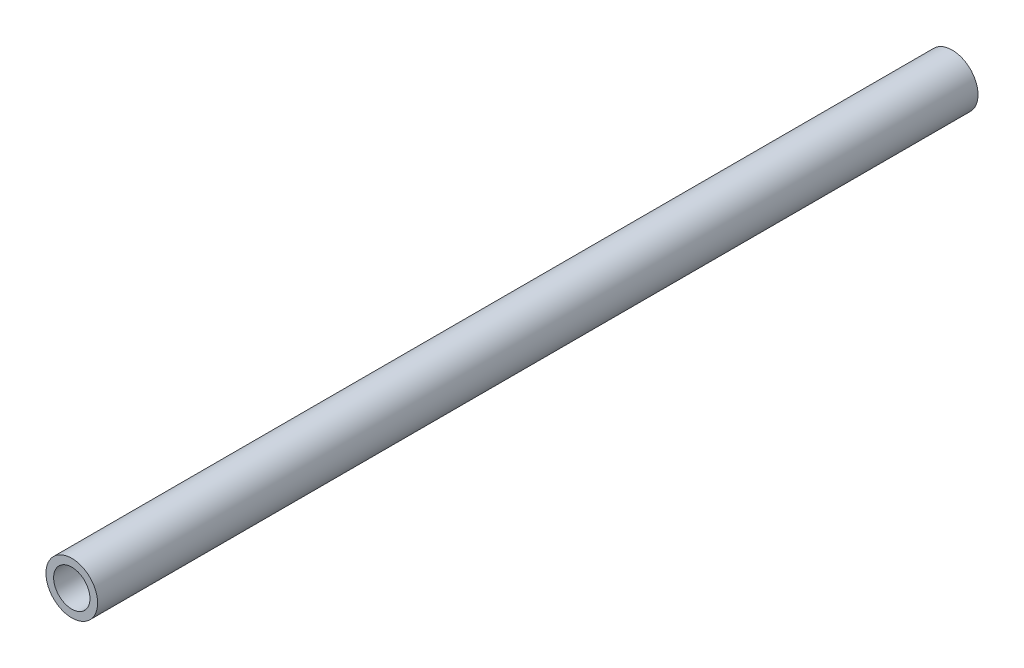
from build123d import *

# Parameters (mm, degrees)
SKETCH1_R           = 13.5
SKETCH1_R_2         = 9.5
BOSS_EXTRUDE1_DEPTH = 460


with BuildPart() as part:
    # Sketch1 → Boss-Extrude1 (new body)
    with BuildSketch(Plane.XY):
        with Locations((347.5, -20)):
            Circle(SKETCH1_R)
        with Locations((347.5, -20)):
            Circle(SKETCH1_R_2, mode=Mode.SUBTRACT)
    extrude(amount=BOSS_EXTRUDE1_DEPTH)


solid = part.part
